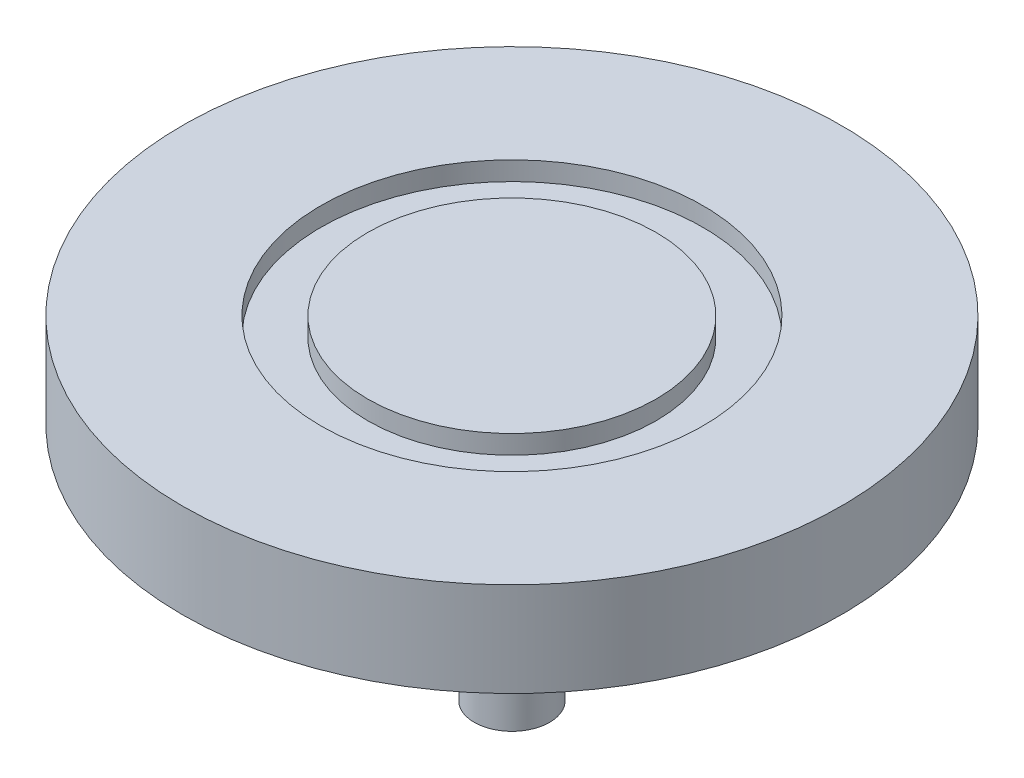
from build123d import *

# Parameters (mm, degrees)
SKETCH1_R           = 35
BOSS_EXTRUDE1_DEPTH = 10
SKETCH2_R           = 20.280215245
SKETCH2_R_2         = 15.321162536
CUT_EXTRUDE1_DEPTH  = 2
SKETCH3_R           = 4
BOSS_EXTRUDE2_DEPTH = 25.4


with BuildPart() as part:
    # Sketch1 → Boss-Extrude1 (new body)
    with BuildSketch(Plane(origin=(0, 0, 0), x_dir=(1, 0, 0), z_dir=(0, 1, 0))):
        Circle(SKETCH1_R)
    extrude(amount=BOSS_EXTRUDE1_DEPTH)

    # Sketch2 → Cut-Extrude1 (cut)
    with BuildSketch(Plane(origin=(0, 10, 0), x_dir=(1, 0, 0), z_dir=(0, 1, 0))):
        Circle(SKETCH2_R)
        Circle(SKETCH2_R_2, mode=Mode.SUBTRACT)
    extrude(amount=-CUT_EXTRUDE1_DEPTH, mode=Mode.SUBTRACT)

    # Sketch3 → Boss-Extrude2 (add)
    with BuildSketch(Plane.XZ):
        Circle(SKETCH3_R)
    extrude(amount=BOSS_EXTRUDE2_DEPTH)


solid = part.part
